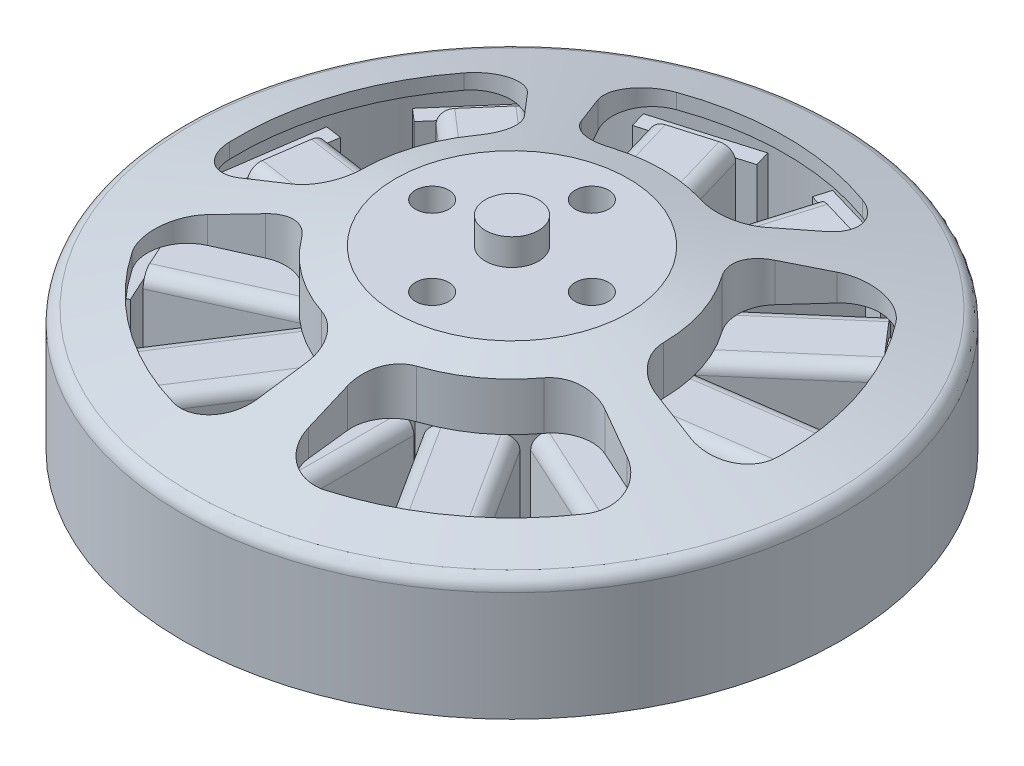
from build123d import *

# Parameters (mm, degrees)
CROQUIS1_R               = 24.75
SALIENTE_EXTRUIR1_DEPTH  = 9
CROQUIS4_R               = 22.838904737
CORTAR_EXTRUIR1_DEPTH    = 9
CORTAR_EXTRUIR2_DEPTH    = 14.3
SALIENTE_EXTRUIR2_START  = -6
CROQUIS3_R               = 2
SALIENTE_EXTRUIR2_DEPTH  = 8
SALIENTE_EXTRUIR3_DEPTH  = 8
CROQUIS7_R               = 7.5
SALIENTE_EXTRUIR4_DEPTH  = 5
CROQUIS8_R               = 12.25
SALIENTE_EXTRUIR5_DEPTH  = 1.2
CROQUIS9_R               = 2
SALIENTE_EXTRUIR6_DEPTH  = 16
CROQUIS11_R              = 1.25
CORTAR_EXTRUIR3_DEPTH    = 3
CROQUIS12_R              = 1.348388042
CORTAR_EXTRUIR4_DEPTH    = 6
SALIENTE_EXTRUIR8_START  = 1
SALIENTE_EXTRUIR8_DEPTH  = 2
CROQUIS14_R              = 2
CORTAR_EXTRUIR5_DEPTH    = 39.2
SALIENTE_EXTRUIR9_START  = -1.5
CROQUIS15_W              = 5.254744746
CROQUIS15_H              = 9.6352304
CROQUIS15_W_2            = 2.30194698
CROQUIS15_H_2            = 8.258288435
SALIENTE_EXTRUIR9_DEPTH  = 10
REDONDEO1_R              = 1
MATRIZC1_COUNT           = 11
MATRIZC1_ANGLE           = 327.5
REDONDEO1_OF_MATRIZC1_R  = 1
REDONDEO2_R              = 1
SALIENTE_EXTRUIR10_START = 2
CROQUIS16_R              = 2
SALIENTE_EXTRUIR10_DEPTH = 24


with BuildPart() as part:
    # Croquis1 → Saliente-Extruir1 (new body)
    with BuildSketch(Plane(origin=(0, 0, 0), x_dir=(1, 0, 0), z_dir=(0, 1, 0))):
        Circle(CROQUIS1_R)
    extrude(amount=SALIENTE_EXTRUIR1_DEPTH)

    # Croquis2 → Revolución1 (revolve)
    with BuildSketch(Plane.XY):
        Polygon((-24.75, 9), (-8.75, 13.3), (0, 13.3), (0, 9), align=None)
    revolve(axis=Axis((0, 13.3, 0), (0, -1, 0)))

    # Croquis4 → Cortar-Extruir1 (cut)
    with BuildSketch(Plane.XZ):
        Circle(CROQUIS4_R)
    extrude(amount=-CORTAR_EXTRUIR1_DEPTH, mode=Mode.SUBTRACT)

    # Croquis5 → Cortar-Extruir2 (cut, through all)
    with BuildSketch(Plane(origin=(0, 13.3, 0), x_dir=(1, 0, 0), z_dir=(0, 1, 0))):
        with BuildLine():
            Line((-8.570425655, 15.0190469), (-6.930143541, 12.144571933))
            ThreePointArc((-6.930143541, 12.144571933), (-5.416422682, 10.837196574), (-3.417344005, 10.7718849))
            ThreePointArc((-3.417344005, 10.7718849), (0, 11.300962098), (3.417344005, 10.7718849))
            ThreePointArc((3.417344005, 10.7718849), (5.416422682, 10.837196574), (6.930143541, 12.144571933))
            Line((6.930143541, 12.144571933), (8.570425655, 15.0190469))
            ThreePointArc((8.570425655, 15.0190469), (8.780099609, 17.542313757), (6.984398181, 19.327333417))
            ThreePointArc((6.984398181, 19.327333417), (0, 20.550611547), (-6.984398181, 19.327333417))
            ThreePointArc((-6.984398181, 19.327333417), (-8.780099609, 17.542313757), (-8.570425655, 15.0190469))
        make_face()
        with BuildLine():
            Line((11.635555246, 12.792099897), (9.408642147, 10.34383729))
            ThreePointArc((9.408642147, 10.34383729), (8.633019762, 8.500201999), (9.188653954, 6.57878278))
            ThreePointArc((9.188653954, 6.57878278), (10.747853644, 3.492189341), (11.3006887, 0.078608211))
            ThreePointArc((11.3006887, 0.078608211), (11.980553077, -1.802446174), (13.691706402, -2.838079057))
            Line((13.691706402, -2.838079057), (16.932369599, -3.509818435))
            ThreePointArc((16.932369599, -3.509818435), (19.396931801, -2.929497875), (20.539684122, -0.670082921))
            ThreePointArc((20.539684122, -0.670082921), (19.544793026, 6.350488213), (16.223088655, 12.615031884))
            ThreePointArc((16.223088655, 12.615031884), (13.970531818, 13.771244019), (11.635555246, 12.792099897))
        make_face()
        with BuildLine():
            Line((15.761594275, -7.113094375), (12.745004176, -5.751728914))
            ThreePointArc((12.745004176, -5.751728914), (10.751922321, -5.583782827), (9.096244459, -6.705973537))
            ThreePointArc((9.096244459, -6.705973537), (6.642538858, -9.14267039), (3.566865708, -10.723302354))
            ThreePointArc((3.566865708, -10.723302354), (1.987966324, -11.951169572), (1.53179638, -13.898601253))
            Line((1.53179638, -13.898601253), (1.894354267, -17.188233987))
            ThreePointArc((1.894354267, -17.188233987), (3.207863522, -19.352843014), (5.709824725, -19.741467437))
            ThreePointArc((5.709824725, -19.741467437), (12.079346393, -16.625793986), (17.010818372, -11.530814943))
            ThreePointArc((17.010818372, -11.530814943), (17.414363114, -9.031216887), (15.761594275, -7.113094375))
        make_face()
        with BuildLine():
            Line((-1.894354267, -17.188233987), (-1.53179638, -13.898601253))
            ThreePointArc((-1.53179638, -13.898601253), (-1.987966324, -11.951169572), (-3.566865708, -10.723302354))
            ThreePointArc((-3.566865708, -10.723302354), (-6.642538858, -9.14267039), (-9.096244459, -6.705973537))
            ThreePointArc((-9.096244459, -6.705973537), (-10.751922321, -5.583782827), (-12.745004176, -5.751728914))
            Line((-12.745004176, -5.751728914), (-15.761594275, -7.113094375))
            ThreePointArc((-15.761594275, -7.113094375), (-17.414363114, -9.031216887), (-17.010818372, -11.530814943))
            ThreePointArc((-17.010818372, -11.530814943), (-12.079346393, -16.625793986), (-5.709824725, -19.741467437))
            ThreePointArc((-5.709824725, -19.741467437), (-3.207863522, -19.352843014), (-1.894354267, -17.188233987))
        make_face()
        with BuildLine():
            Line((-16.932369599, -3.509818435), (-13.691706402, -2.838079057))
            ThreePointArc((-13.691706402, -2.838079057), (-11.980553077, -1.802446174), (-11.3006887, 0.078608211))
            ThreePointArc((-11.3006887, 0.078608211), (-10.747853644, 3.492189341), (-9.188653954, 6.57878278))
            ThreePointArc((-9.188653954, 6.57878278), (-8.633019762, 8.500201999), (-9.408642147, 10.34383729))
            Line((-9.408642147, 10.34383729), (-11.635555246, 12.792099897))
            ThreePointArc((-11.635555246, 12.792099897), (-13.970531818, 13.771244019), (-16.223088655, 12.615031884))
            ThreePointArc((-16.223088655, 12.615031884), (-19.544793026, 6.350488213), (-20.539684122, -0.670082921))
            ThreePointArc((-20.539684122, -0.670082921), (-19.396931801, -2.929497875), (-16.932369599, -3.509818435))
        make_face()
    extrude(amount=-CORTAR_EXTRUIR2_DEPTH, mode=Mode.SUBTRACT)

    # Croquis3 → Saliente-Extruir2 (add)
    with BuildSketch(Plane(origin=(0, 13.3, 0), x_dir=(1, 0, 0), z_dir=(0, 1, 0)).offset(SALIENTE_EXTRUIR2_START)):
        Circle(CROQUIS3_R)
    extrude(amount=SALIENTE_EXTRUIR2_DEPTH)

    # Croquis6 → Saliente-Extruir3 (add)
    with BuildSketch(Plane.XZ.offset(-7.3)):
        with BuildLine():
            Line((-1.41776314, 20.230911324), (-1.41776314, 8.691927398))
            ThreePointArc((-1.41776314, 8.691927398), (-2.48116113, 8.450058797), (-3.506512483, 8.078615254))
            Line((-3.506512483, 8.078615254), (-9.744958186, 17.785826247))
            Line((-9.744958186, 17.785826247), (-7.771261406, 19.054244148))
            Line((-7.771261406, 19.054244148), (-8.431305766, 20.08129322))
            Line((-8.431305766, 20.08129322), (-14.764095827, 16.011456172))
            Line((-14.764095827, 16.011456172), (-14.104051466, 14.984407099))
            Line((-14.104051466, 14.984407099), (-12.130354686, 16.252825001))
            Line((-12.130354686, 16.252825001), (-5.891908984, 6.545614008))
            ThreePointArc((-5.891908984, 6.545614008), (-6.655732261, 5.767224834), (-7.317495169, 4.900399847))
            Line((-7.317495169, 4.900399847), (-17.813724142, 9.693867005))
            Line((-17.813724142, 9.693867005), (-16.839103244, 11.827989086))
            Line((-16.839103244, 11.827989086), (-17.949632544, 12.335150824))
            Line((-17.949632544, 12.335150824), (-21.076794527, 5.487621234))
            Line((-21.076794527, 5.487621234), (-19.966265227, 4.980459496))
            Line((-19.966265227, 4.980459496), (-18.991644329, 7.114581576))
            Line((-18.991644329, 7.114581576), (-8.495415356, 2.321114419))
            ThreePointArc((-8.495415356, 2.321114419), (-8.717155427, 1.253337736), (-8.805224842, 0.166342114))
            Line((-8.805224842, 0.166342114), (-20.226758549, -1.475826517))
            Line((-20.226758549, -1.475826517), (-20.560648782, 0.846431062))
            Line((-20.560648782, 0.846431062), (-21.769077816, 0.672685197))
            Line((-21.769077816, 0.672685197), (-20.697759886, -6.778494673))
            Line((-20.697759886, -6.778494673), (-19.489330852, -6.604748808))
            Line((-19.489330852, -6.604748808), (-19.823221085, -4.282491229))
            Line((-19.823221085, -4.282491229), (-8.401687378, -2.640322598))
            ThreePointArc((-8.401687378, -2.640322598), (-8.010943337, -3.658475238), (-7.497357842, -4.620528066))
            Line((-7.497357842, -4.620528066), (-16.217940032, -12.176955548))
            Line((-16.217940032, -12.176955548), (-17.754333606, -10.403862844))
            Line((-17.754333606, -10.403862844), (-18.676994694, -11.203353227))
            Line((-18.676994694, -11.203353227), (-13.747332725, -16.892486415))
            Line((-13.747332725, -16.892486415), (-12.824671637, -16.092996032))
            Line((-12.824671637, -16.092996032), (-14.361065211, -14.319903328))
            Line((-14.361065211, -14.319903328), (-5.640483021, -6.763475845))
            ThreePointArc((-5.640483021, -6.763475845), (-4.761313341, -7.408748173), (-3.809132701, -7.940413231))
            Line((-3.809132701, -7.940413231), (-7.060040146, -19.011987231))
            Line((-7.060040146, -19.011987231), (-9.311142957, -18.351003807))
            Line((-9.311142957, -18.351003807), (-9.655097722, -19.522406161))
            Line((-9.655097722, -19.522406161), (-2.432224557, -21.643233077))
            Line((-2.432224557, -21.643233077), (-2.088269792, -20.471830723))
            Line((-2.088269792, -20.471830723), (-4.339372603, -19.8108473))
            Line((-4.339372603, -19.8108473), (-1.088465159, -8.7392733))
            ThreePointArc((-1.088465159, -8.7392733), (0, -8.806795911), (1.088465159, -8.7392733))
            Line((1.088465159, -8.7392733), (4.339372603, -19.8108473))
            Line((4.339372603, -19.8108473), (2.088269792, -20.471830723))
            Line((2.088269792, -20.471830723), (2.432224557, -21.643233077))
            Line((2.432224557, -21.643233077), (9.655097722, -19.522406161))
            Line((9.655097722, -19.522406161), (9.311142957, -18.351003807))
            Line((9.311142957, -18.351003807), (7.060040146, -19.011987231))
            Line((7.060040146, -19.011987231), (3.809132701, -7.940413231))
            ThreePointArc((3.809132701, -7.940413231), (4.761313341, -7.408748173), (5.640483021, -6.763475845))
            Line((5.640483021, -6.763475845), (14.361065211, -14.319903328))
            Line((14.361065211, -14.319903328), (12.824671637, -16.092996032))
            Line((12.824671637, -16.092996032), (13.747332725, -16.892486415))
            Line((13.747332725, -16.892486415), (18.676994694, -11.203353227))
            Line((18.676994694, -11.203353227), (17.754333606, -10.403862844))
            Line((17.754333606, -10.403862844), (16.217940032, -12.176955548))
            Line((16.217940032, -12.176955548), (7.497357842, -4.620528066))
            ThreePointArc((7.497357842, -4.620528066), (8.010943337, -3.658475238), (8.401687378, -2.640322598))
            Line((8.401687378, -2.640322598), (19.823221085, -4.282491229))
            Line((19.823221085, -4.282491229), (19.489330852, -6.604748808))
            Line((19.489330852, -6.604748808), (20.697759886, -6.778494673))
            Line((20.697759886, -6.778494673), (21.769077816, 0.672685197))
            Line((21.769077816, 0.672685197), (20.560648782, 0.846431062))
            Line((20.560648782, 0.846431062), (20.226758549, -1.475826517))
            Line((20.226758549, -1.475826517), (8.805224842, 0.166342114))
            ThreePointArc((8.805224842, 0.166342114), (8.717155427, 1.253337736), (8.495415356, 2.321114419))
            Line((8.495415356, 2.321114419), (18.991644329, 7.114581576))
            Line((18.991644329, 7.114581576), (19.966265227, 4.980459496))
            Line((19.966265227, 4.980459496), (21.076794527, 5.487621234))
            Line((21.076794527, 5.487621234), (17.949632544, 12.335150824))
            Line((17.949632544, 12.335150824), (16.839103244, 11.827989086))
            Line((16.839103244, 11.827989086), (17.813724142, 9.693867005))
            Line((17.813724142, 9.693867005), (7.317495169, 4.900399847))
            ThreePointArc((7.317495169, 4.900399847), (6.655732261, 5.767224834), (5.891908984, 6.545614008))
            Line((5.891908984, 6.545614008), (12.130354686, 16.252825001))
            Line((12.130354686, 16.252825001), (14.104051466, 14.984407099))
            Line((14.104051466, 14.984407099), (14.764095827, 16.011456172))
            Line((14.764095827, 16.011456172), (8.431305766, 20.08129322))
            Line((8.431305766, 20.08129322), (7.771261406, 19.054244148))
            Line((7.771261406, 19.054244148), (9.744958186, 17.785826247))
            Line((9.744958186, 17.785826247), (3.506512483, 8.078615254))
            ThreePointArc((3.506512483, 8.078615254), (2.48116113, 8.450058797), (1.41776314, 8.691927398))
            Line((1.41776314, 8.691927398), (1.41776314, 20.230911324))
            Line((1.41776314, 20.230911324), (3.76390102, 20.230911324))
            Line((3.76390102, 20.230911324), (3.76390102, 21.451766907))
            Line((3.76390102, 21.451766907), (-3.76390102, 21.451766907))
            Line((-3.76390102, 21.451766907), (-3.76390102, 20.230911324))
            Line((-3.76390102, 20.230911324), (-1.41776314, 20.230911324))
        make_face()
    extrude(amount=SALIENTE_EXTRUIR3_DEPTH)

    # Croquis7 → Saliente-Extruir4 (add)
    with BuildSketch(Plane.XZ.offset(0.7)):
        Circle(CROQUIS7_R)
    extrude(amount=SALIENTE_EXTRUIR4_DEPTH)

    # Croquis8 → Saliente-Extruir5 (add)
    with BuildSketch(Plane.XZ.offset(5.7)):
        Circle(CROQUIS8_R)
    extrude(amount=SALIENTE_EXTRUIR5_DEPTH)

    # Croquis9 → Saliente-Extruir6 (add)
    with BuildSketch(Plane.XZ.offset(6.9)):
        Circle(CROQUIS9_R)
    extrude(amount=SALIENTE_EXTRUIR6_DEPTH)

    # Croquis11 → Cortar-Extruir3 (cut)
    with BuildSketch(Plane(origin=(0, 13.3, 0), x_dir=(1, 0, 0), z_dir=(0, 1, 0))):
        with Locations((0, -6)):
            Circle(CROQUIS11_R)
        with Locations((6, 0)):
            Circle(CROQUIS11_R)
        with Locations((0, 6)):
            Circle(CROQUIS11_R)
        with Locations((-6, 0)):
            Circle(CROQUIS11_R)
    extrude(amount=-CORTAR_EXTRUIR3_DEPTH, mode=Mode.SUBTRACT)

    # Croquis12 → Cortar-Extruir4 (cut)
    with BuildSketch(Plane.XZ.offset(6.9)):
        with Locations((0, 8)):
            Circle(CROQUIS12_R)
        with Locations((0, -8)):
            Circle(CROQUIS12_R)
        with Locations((-9.5, 0)):
            Circle(CROQUIS12_R)
        with Locations((9.5, 0)):
            Circle(CROQUIS12_R)
    extrude(amount=-CORTAR_EXTRUIR4_DEPTH, mode=Mode.SUBTRACT)

    # Croquis13 → Saliente-Extruir8 (add)
    with BuildSketch(Plane(origin=(0, -5.7, 0), x_dir=(1, 0, 0), z_dir=(0, 1, 0)).offset(SALIENTE_EXTRUIR8_START)):
        Polygon((-6.908867887, 2.747843539), (-3.184587628, 6.472123798), (-16.034776003, 19.322312173), (-19.759056262, 15.598031914), align=None)
    extrude(amount=SALIENTE_EXTRUIR8_DEPTH)

    # Croquis14 → Cortar-Extruir5 (cut, through all)
    with BuildSketch(Plane(origin=(0, 15.3, 0), x_dir=(1, 0, 0), z_dir=(0, 1, 0))):
        Circle(CROQUIS14_R)
    extrude(amount=-CORTAR_EXTRUIR5_DEPTH, mode=Mode.SUBTRACT)

    # Croquis15 → Saliente-Extruir9 (add)
    with BuildSketch(Plane(origin=(-21.233418851, 0, -3.052904738), x_dir=(-0.142314838, 0, 0.989821442), z_dir=(-0.989821442, 0, -0.142314838)).offset(SALIENTE_EXTRUIR9_START)):
        with Locations((0, 3.429144218)):
            Rectangle(CROQUIS15_W, CROQUIS15_H)
        with Locations((0, 3.429144218)):
            Rectangle(CROQUIS15_W_2, CROQUIS15_H_2, mode=Mode.SUBTRACT)
    saliente_extruir9 = extrude(amount=-SALIENTE_EXTRUIR9_DEPTH)

    # Redondeo1
    redondeo1_edges = [part.edges().sort_by_distance(p)[0] for p in [
        (-15.173493553, 8.246759418, 0.472771222),
        (-15.173493553, -1.388470982, 0.472771222),
        (-14.425665404, -1.388470982, -4.7284878),
        (-14.425665404, 8.246759418, -4.7284878),
    ]]
    fillet(redondeo1_edges, radius=REDONDEO1_R)

    # MatrizC1: Saliente-Extruir9 ×11 about axis
    matrizc1_axis = Axis((0, 14.31, 0), (0, -1, 0))
    for i in range(1, MATRIZC1_COUNT):
        add(saliente_extruir9.rotate(matrizc1_axis, i * MATRIZC1_ANGLE / (MATRIZC1_COUNT - 1)))

    # Redondeo1 of MatrizC1
    redondeo1_of_matrizc1_edges = [part.edges().sort_by_distance(p)[0] for p in [
        (-13.017257203, 8.246759418, -7.810853612),
        (-13.017257203, -1.388470982, -7.810853612),
        (-9.574556205, -1.388470982, -11.780759429),
        (-9.574556205, 8.246759418, -11.780759429),
        (-6.722548746, 8.246759418, -13.611236446),
        (-6.722548746, -1.388470982, -13.611236446),
        (-1.679485196, -1.388470982, -15.087668763),
        (-1.679485196, 8.246759418, -15.087668763),
        (1.70940568, 8.246759418, -15.08430812),
        (1.70940568, -1.388470982, -15.08430812),
        (6.749531062, -1.388470982, -13.597876661),
        (6.749531062, 8.246759418, -13.597876661),
        (9.597902477, 8.246759418, -11.761746779),
        (9.597902477, -1.388470982, -11.761746779),
        (13.03272308, -1.388470982, -7.785020767),
        (13.03272308, 8.246759418, -7.785020767),
        (14.435015171, 8.246759418, -4.699867683),
        (14.435015171, -1.388470982, -4.699867683),
        (15.17252605, -1.388470982, 0.502864297),
        (15.17252605, 8.246759418, 0.502864297),
        (14.682919347, 8.246759418, 3.856202624),
        (14.682919347, -1.388470982, 3.856202624),
        (12.488649586, -1.388470982, 8.630877751),
        (12.488649586, 8.246759418, 8.630877751),
        (10.262800819, 8.246759418, 11.186301381),
        (10.262800819, -1.388470982, 11.186301381),
        (5.834356992, -1.388470982, 14.014945513),
        (5.834356992, 8.246759418, 14.014945513),
        (2.579912395, 8.246759418, 14.96002912),
        (2.579912395, -1.388470982, 14.96002912),
        (-2.674805894, -1.388470982, 14.94335413),
        (-2.674805894, 8.246759418, 14.94335413),
        (-5.923186871, 8.246759418, 13.977634869),
        (-5.923186871, -1.388470982, 13.977634869),
        (-10.33358921, -1.388470982, 11.120942103),
        (-10.33358921, 8.246759418, 11.120942103),
        (-12.543174874, 8.246759418, 8.551443347),
        (-12.543174874, -1.388470982, 8.551443347),
        (-14.707097445, -1.388470982, 3.76293821),
        (-14.707097445, 8.246759418, 3.76293821),
    ]]
    fillet(redondeo1_of_matrizc1_edges, radius=REDONDEO1_OF_MATRIZC1_R)

    # Redondeo2
    redondeo2_edges = [part.edges().sort_by_distance(p)[0] for p in [
        (0, 9, 24.75),
    ]]
    fillet(redondeo2_edges, radius=REDONDEO2_R)

    # Croquis16 → Saliente-Extruir10 (add)
    with BuildSketch(Plane(origin=(0, 13.3, 0), x_dir=(1, 0, 0), z_dir=(0, 1, 0)).offset(SALIENTE_EXTRUIR10_START)):
        Circle(CROQUIS16_R)
    extrude(amount=-SALIENTE_EXTRUIR10_DEPTH)


solid = part.part
